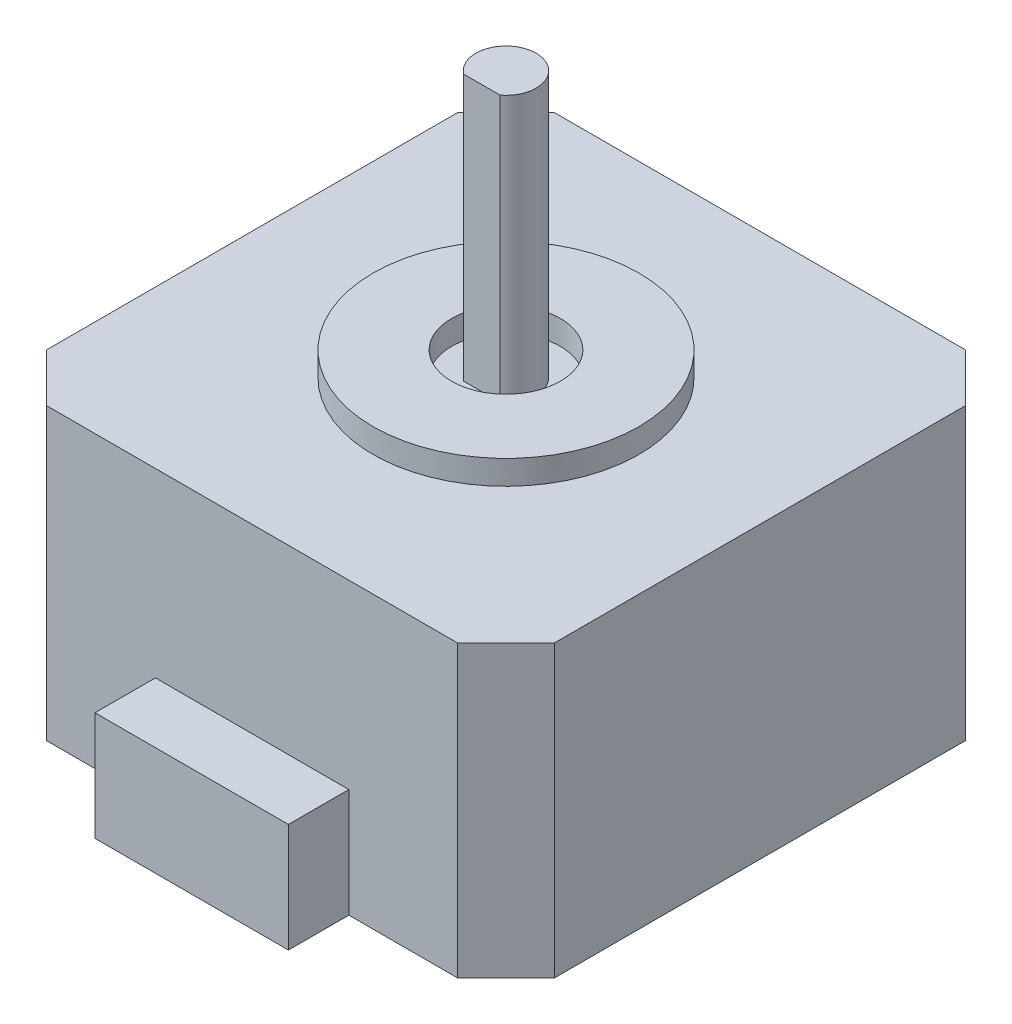
from build123d import *

# Parameters (mm, degrees)
SKETCH1_W           = 42
SKETCH1_H           = 42
BOSS_EXTRUDE1_DEPTH = 24
SKETCH2_W           = 16
SKETCH2_H           = 9
BOSS_EXTRUDE2_DEPTH = 5
SKETCH3_R           = 11
SKETCH3_R_2         = 4.5
BOSS_EXTRUDE4_DEPTH = 2
BOSS_EXTRUDE5_DEPTH = 22
CHAMFER1_SIZE       = 4
CHAMFER2_SIZE       = 4
CHAMFER3_SIZE       = 4
CHAMFER4_SIZE       = 4


with BuildPart() as part:
    # Sketch1 → Boss-Extrude1 (new body)
    with BuildSketch(Plane(origin=(0, 0, 0), x_dir=(1, 0, 0), z_dir=(0, 1, 0))):
        with Locations((21, 21)):
            Rectangle(SKETCH1_W, SKETCH1_H)
    extrude(amount=BOSS_EXTRUDE1_DEPTH)

    # Sketch2 → Boss-Extrude2 (add)
    with BuildSketch(Plane.XY):
        with Locations((21, 4.5)):
            Rectangle(SKETCH2_W, SKETCH2_H)
    extrude(amount=BOSS_EXTRUDE2_DEPTH)

    # Sketch3 → Boss-Extrude4 (add)
    with BuildSketch(Plane(origin=(0, 24, 0), x_dir=(1, 0, 0), z_dir=(0, 1, 0))):
        with Locations((21, 21)):
            Circle(SKETCH3_R)
        with Locations((21, 21)):
            Circle(SKETCH3_R_2, mode=Mode.SUBTRACT)
    extrude(amount=BOSS_EXTRUDE4_DEPTH)

    # Sketch4 → Boss-Extrude5 (add)
    with BuildSketch(Plane(origin=(0, 24, 0), x_dir=(1, 0, 0), z_dir=(0, 1, 0))):
        with BuildLine():
            Line((19.5, 19), (22.5, 19))
            ThreePointArc((22.5, 19), (21, 23.5), (19.5, 19))
        make_face()
    extrude(amount=BOSS_EXTRUDE5_DEPTH)

    # Chamfer1
    chamfer1_edges = [part.edges().sort_by_distance(p)[0] for p in [
        (0, 12, 0),
    ]]
    chamfer(chamfer1_edges, length=CHAMFER1_SIZE)

    # Chamfer2
    chamfer2_edges = [part.edges().sort_by_distance(p)[0] for p in [
        (42, 12, 0),
    ]]
    chamfer(chamfer2_edges, length=CHAMFER2_SIZE)

    # Chamfer3
    chamfer3_edges = [part.edges().sort_by_distance(p)[0] for p in [
        (42, 12, -42),
    ]]
    chamfer(chamfer3_edges, length=CHAMFER3_SIZE)

    # Chamfer4
    chamfer4_edges = [part.edges().sort_by_distance(p)[0] for p in [
        (0, 12, -42),
    ]]
    chamfer(chamfer4_edges, length=CHAMFER4_SIZE)


solid = part.part
